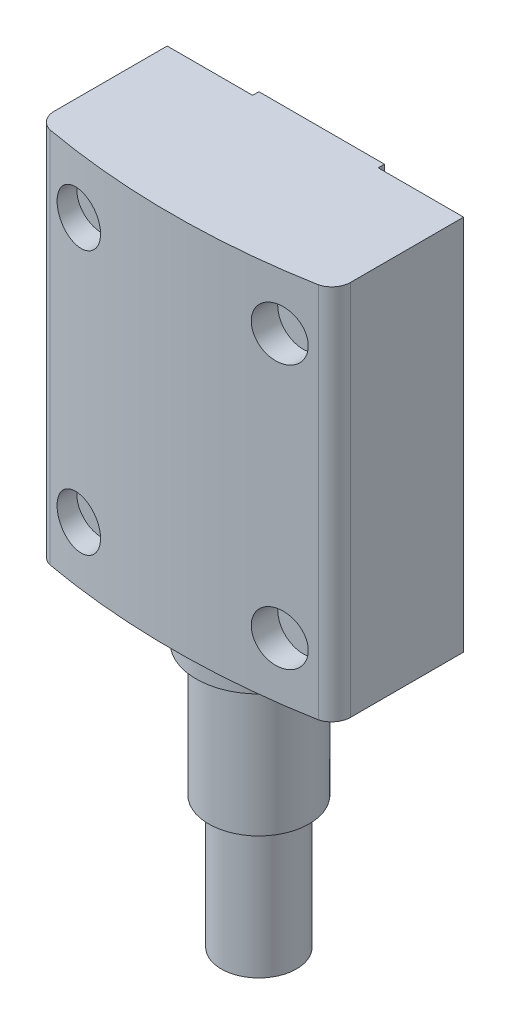
from build123d import *

# Parameters (mm, degrees)
SKETCH_1_W          = 10
SKETCH_1_H          = 0.5
EXTRUDE_3_DEPTH     = 30
SKETCH_4_R          = 5
EXTRUDE_4_DEPTH     = 3
SKETCH_5_R          = 4
EXTRUDE_5_DEPTH     = 10.5
SKETCH_6_R          = 3
EXTRUDE_6_DEPTH     = 10.5
CUT_EXTRUDE_2_REACH = 4.408
SKETCH_9_R          = 2


with BuildPart() as part:
    # ｽｹｯﾁ1 → ﾎﾞｽ - 押し出し3 (new body)
    with BuildSketch(Plane(origin=(0, 0, 0), x_dir=(1, 0, 0), z_dir=(0, 1, 0))):
        with BuildLine():
            Line((-5, 4.5), (-11.8, 4.5))
            Line((-11.8, 4.5), (-11.8, -4.5))
            Line((-11.8, -4.5), (0, -4.5))
            ThreePointArc((0, -4.5), (-3.535533906, -3.035533906), (-5, 0.5))
            Line((-5, 0.5), (-5, 4.5))
        make_face()
        with BuildLine():
            Line((5, 4.5), (-5, 4.5))
            Line((-5, 4.5), (-5, 0.5))
            ThreePointArc((-5, 0.5), (-3.535533906, -3.035533906), (0, -4.5))
            ThreePointArc((0, -4.5), (3.535533906, -3.035533906), (5, 0.5))
            Line((5, 0.5), (5, 4.5))
        make_face()
        with BuildLine():
            Line((11.8, 4.5), (5, 4.5))
            Line((5, 4.5), (5, 0.5))
            ThreePointArc((5, 0.5), (3.535533906, -3.035533906), (0, -4.5))
            Line((0, -4.5), (11.8, -4.5))
            Line((11.8, -4.5), (11.8, 4.5))
        make_face()
        with BuildLine():
            ThreePointArc((-11.8, -4.5), (-11.49003001, -5.413142144), (-10.688228568, -5.948888739))
            ThreePointArc((-10.688228568, -5.948888739), (0, -6.908263067), (10.688228568, -5.948888739))
            ThreePointArc((10.688228568, -5.948888739), (11.49003001, -5.413142144), (11.8, -4.5))
            Line((11.8, -4.5), (-11.8, -4.5))
        make_face()
        with Locations((0, 4.75)):
            Rectangle(SKETCH_1_W, SKETCH_1_H)
    extrude(amount=EXTRUDE_3_DEPTH)

    # ｽｹｯﾁ4 → ﾎﾞｽ - 押し出し4 (add)
    with BuildSketch(Plane.XZ):
        Circle(SKETCH_4_R)
    extrude(amount=EXTRUDE_4_DEPTH)

    # ｽｹｯﾁ5 → ﾎﾞｽ - 押し出し5 (add)
    with BuildSketch(Plane.XZ.offset(3)):
        Circle(SKETCH_5_R)
    extrude(amount=EXTRUDE_5_DEPTH)

    # ｽｹｯﾁ6 → ﾎﾞｽ - 押し出し6 (add)
    with BuildSketch(Plane.XZ.offset(13.5)):
        Circle(SKETCH_6_R)
    extrude(amount=EXTRUDE_6_DEPTH)

    # ｽｹｯﾁ9 → ｶｯﾄ - 押し出し2 (cut, up to next)
    with BuildSketch(Plane(origin=(0, 0, 4.5), x_dir=(-1, 0, 0), z_dir=(0, 0, -1)), mode=Mode.PRIVATE) as cut_extrude_2_sk1:
        with Locations((-8, 4.5)):
            Circle(SKETCH_9_R)
    cut_extrude_2_tool1 = extrude(cut_extrude_2_sk1.sketch, amount=-CUT_EXTRUDE_2_REACH, mode=Mode.PRIVATE) & part.part
    add(cut_extrude_2_tool1.solids().sort_by_distance((8, 4.5, 4.5))[0], mode=Mode.SUBTRACT)
    # ｽｹｯﾁ9 → ｶｯﾄ - 押し出し2 (cut, up to next)
    with BuildSketch(Plane(origin=(0, 0, 4.5), x_dir=(-1, 0, 0), z_dir=(0, 0, -1)), mode=Mode.PRIVATE) as cut_extrude_2_sk2:
        with Locations((8, 4.5)):
            Circle(SKETCH_9_R)
    cut_extrude_2_tool2 = extrude(cut_extrude_2_sk2.sketch, amount=-CUT_EXTRUDE_2_REACH, mode=Mode.PRIVATE) & part.part
    add(cut_extrude_2_tool2.solids().sort_by_distance((-8, 4.5, 4.5))[0], mode=Mode.SUBTRACT)
    # ｽｹｯﾁ9 → ｶｯﾄ - 押し出し2 (cut, up to next)
    with BuildSketch(Plane(origin=(0, 0, 4.5), x_dir=(-1, 0, 0), z_dir=(0, 0, -1)), mode=Mode.PRIVATE) as cut_extrude_2_sk3:
        with Locations((8, 25.5)):
            Circle(SKETCH_9_R)
    cut_extrude_2_tool3 = extrude(cut_extrude_2_sk3.sketch, amount=-CUT_EXTRUDE_2_REACH, mode=Mode.PRIVATE) & part.part
    add(cut_extrude_2_tool3.solids().sort_by_distance((-8, 25.5, 4.5))[0], mode=Mode.SUBTRACT)
    # ｽｹｯﾁ9 → ｶｯﾄ - 押し出し2 (cut, up to next)
    with BuildSketch(Plane(origin=(0, 0, 4.5), x_dir=(-1, 0, 0), z_dir=(0, 0, -1)), mode=Mode.PRIVATE) as cut_extrude_2_sk4:
        with Locations((-8, 25.5)):
            Circle(SKETCH_9_R)
    cut_extrude_2_tool4 = extrude(cut_extrude_2_sk4.sketch, amount=-CUT_EXTRUDE_2_REACH, mode=Mode.PRIVATE) & part.part
    add(cut_extrude_2_tool4.solids().sort_by_distance((8, 25.5, 4.5))[0], mode=Mode.SUBTRACT)


solid = part.part
